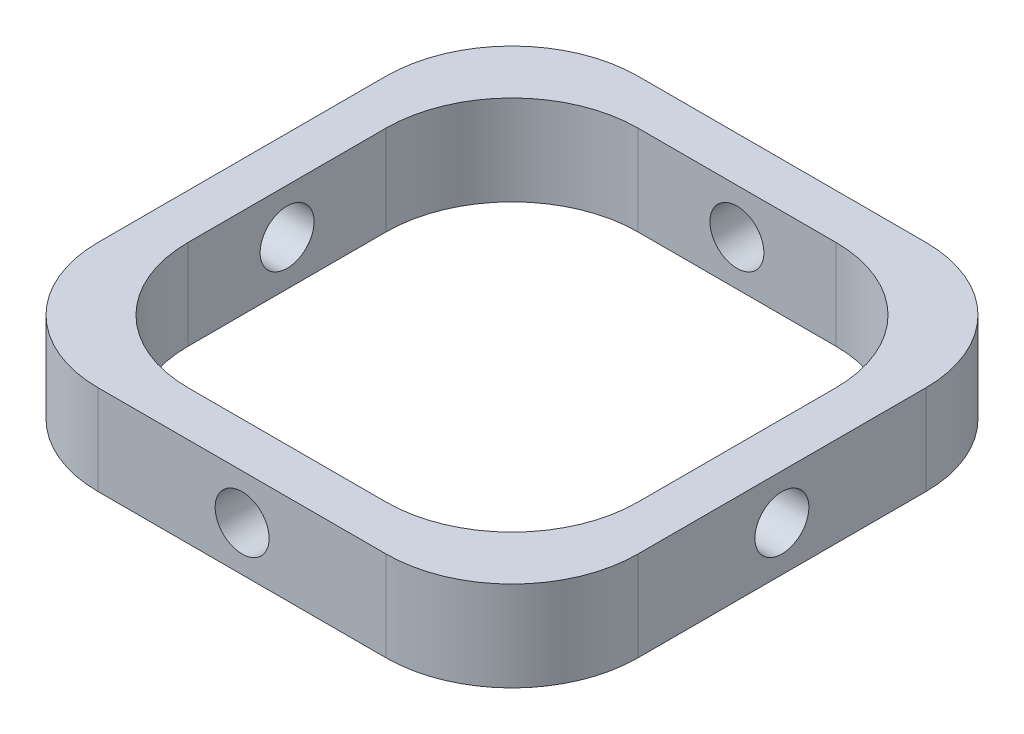
from build123d import *

# Parameters (mm, degrees)
CROQUIS1_W                 = 30
CROQUIS1_H                 = 30
CROQUIS1_W_2               = 25
CROQUIS1_H_2               = 25
SALIENTE_EXTRUIR1_DEPTH    = 5
CROQUIS2_R                 = 1.5
CORTAR_EXTRUIR1_DEPTH      = 1
CORTAR_EXTRUIR1_DEPTH_BACK = 31
CROQUIS3_R                 = 1.5
CORTAR_EXTRUIR2_DEPTH      = 1
CORTAR_EXTRUIR2_DEPTH_BACK = 31
REDONDEO1_R                = 7


with BuildPart() as part:
    # Croquis1 → Saliente-Extruir1 (new body)
    with BuildSketch(Plane(origin=(0, 0, 0), x_dir=(1, 0, 0), z_dir=(0, 1, 0))):
        Rectangle(CROQUIS1_W, CROQUIS1_H)
        Rectangle(CROQUIS1_W_2, CROQUIS1_H_2, mode=Mode.SUBTRACT)
    extrude(amount=SALIENTE_EXTRUIR1_DEPTH)

    # Croquis2 → Cortar-Extruir1 (cut, two sides)
    with BuildSketch(Plane.XY.offset(15)) as cortar_extruir1_sk:
        with Locations((0, 2.5)):
            Circle(CROQUIS2_R)
    extrude(amount=CORTAR_EXTRUIR1_DEPTH, mode=Mode.SUBTRACT)
    extrude(cortar_extruir1_sk.sketch, amount=-CORTAR_EXTRUIR1_DEPTH_BACK, mode=Mode.SUBTRACT)

    # Croquis3 → Cortar-Extruir2 (cut, two sides)
    with BuildSketch(Plane.ZY.offset(15)) as cortar_extruir2_sk:
        with Locations((0, 2.5)):
            Circle(CROQUIS3_R)
    extrude(amount=CORTAR_EXTRUIR2_DEPTH, mode=Mode.SUBTRACT)
    extrude(cortar_extruir2_sk.sketch, amount=-CORTAR_EXTRUIR2_DEPTH_BACK, mode=Mode.SUBTRACT)

    # Redondeo1
    redondeo1_edges = [part.edges().sort_by_distance(p)[0] for p in [
        (-12.5, 2.5, -12.5),
        (-12.5, 2.5, 12.5),
        (12.5, 2.5, 12.5),
        (12.5, 2.5, -12.5),
        (15, 2.5, 15),
        (-15, 2.5, 15),
        (-15, 2.5, -15),
        (15, 2.5, -15),
    ]]
    fillet(redondeo1_edges, radius=REDONDEO1_R)


solid = part.part
